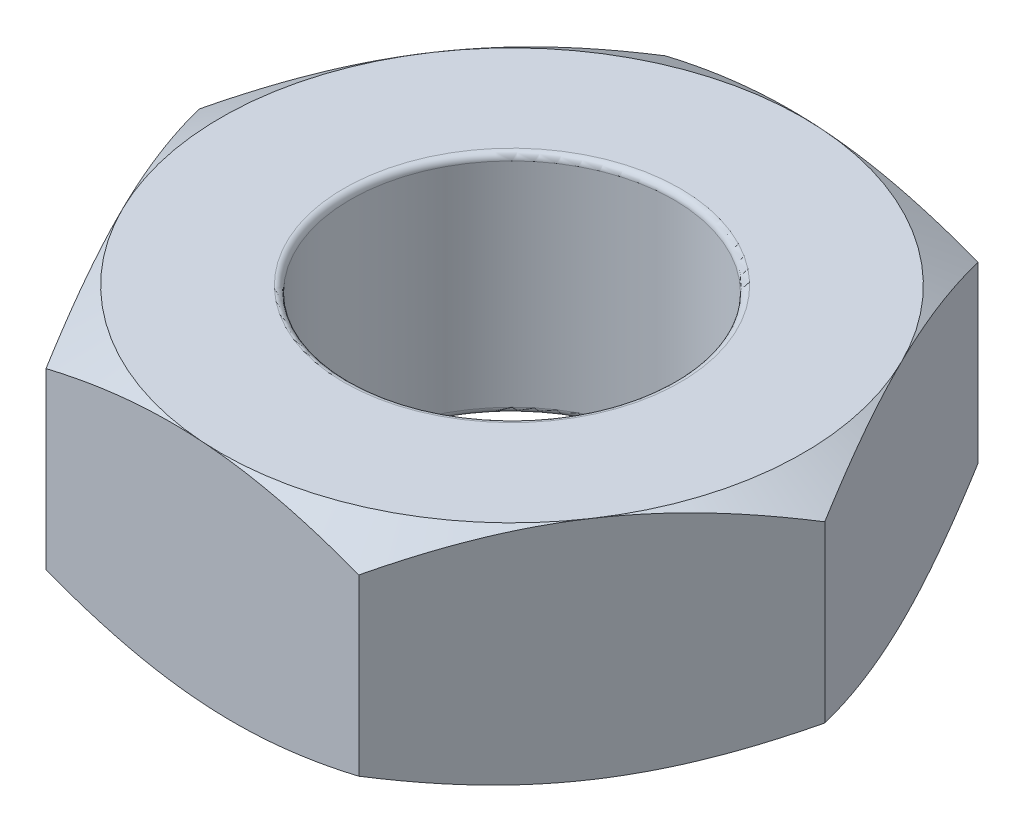
from build123d import *

# Parameters (mm, degrees)
SKETCH1_R           = 1.25
BOSS_EXTRUDE1_DEPTH = 1.75
SKETCH2_OUTSIDE_W   = 15.55
SKETCH2_OUTSIDE_H   = 15.03
SKETCH2_OUTSIDE_R   = 2.25
CUT_EXTRUDE1_DEPTH  = 2
CUT_EXTRUDE1_TAPER  = 60
SKETCH3_OUTSIDE_W   = 15.55
SKETCH3_OUTSIDE_H   = 15.03
SKETCH3_OUTSIDE_R   = 2.25
CUT_EXTRUDE2_DEPTH  = 2
CUT_EXTRUDE2_TAPER  = 60
FILLET1_R           = 0.05


with BuildPart() as part:
    # Sketch1 → Boss-Extrude1 (new body)
    with BuildSketch(Plane(origin=(0, 0, 0), x_dir=(1, 0, 0), z_dir=(0, 1, 0))):
        Polygon((-2.592304058, 0.173088625), (-1.446051175, -2.158456856), (1.146252883, -2.331545481), (2.592304058, -0.173088625), (1.446051175, 2.158456856), (-1.146252883, 2.331545481), align=None)
        Circle(SKETCH1_R, mode=Mode.SUBTRACT)
    extrude(amount=BOSS_EXTRUDE1_DEPTH)

    # Sketch2 outside → Cut-Extrude1 (cut)
    with BuildSketch(Plane(origin=(0, 1.75, 0), x_dir=(1, 0, 0), z_dir=(0, 1, 0))):
        Rectangle(SKETCH2_OUTSIDE_W, SKETCH2_OUTSIDE_H)
        Circle(SKETCH2_OUTSIDE_R, mode=Mode.SUBTRACT)
    extrude(amount=-CUT_EXTRUDE1_DEPTH, taper=CUT_EXTRUDE1_TAPER, mode=Mode.SUBTRACT)

    # Sketch3 outside → Cut-Extrude2 (cut)
    with BuildSketch(Plane.XZ):
        Rectangle(SKETCH3_OUTSIDE_W, SKETCH3_OUTSIDE_H)
        Circle(SKETCH3_OUTSIDE_R, mode=Mode.SUBTRACT)
    extrude(amount=-CUT_EXTRUDE2_DEPTH, taper=CUT_EXTRUDE2_TAPER, mode=Mode.SUBTRACT)

    # Fillet1
    fillet1_edges = [part.edges().sort_by_distance(p)[0] for p in [
        (-1.25, 0, 0),
        (-1.25, 1.75, 0),
    ]]
    fillet(fillet1_edges, radius=FILLET1_R)


solid = part.part
